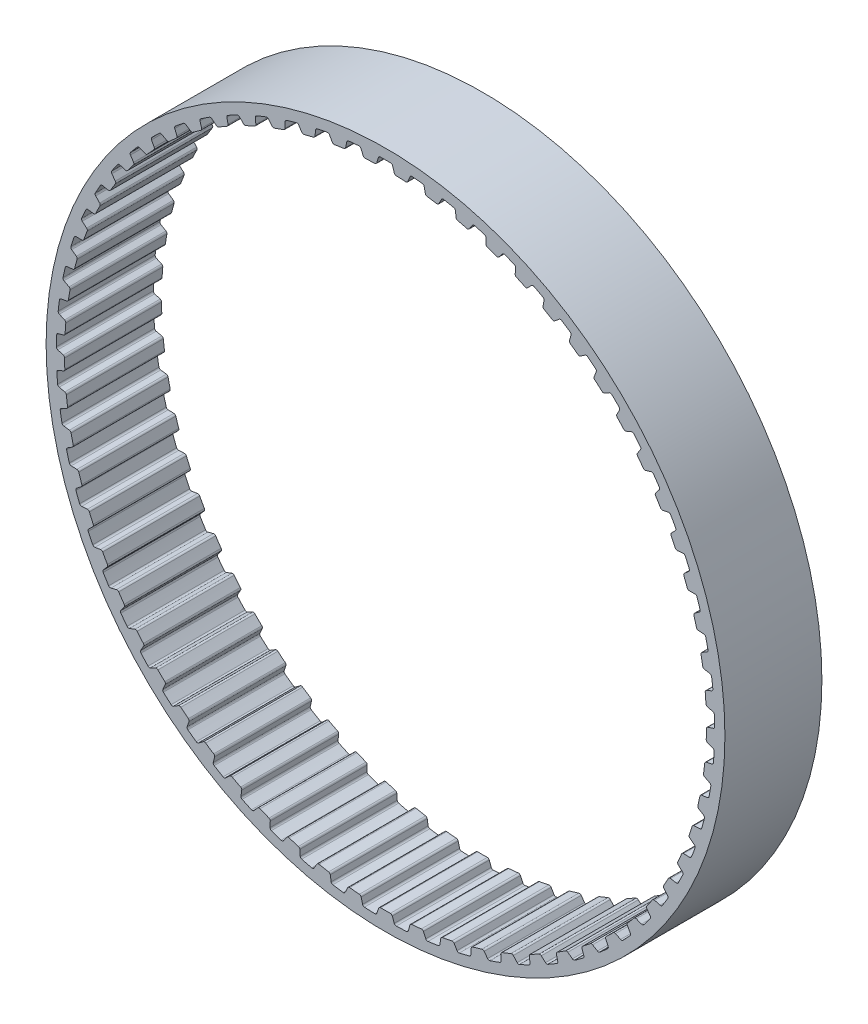
from build123d import *

# Parameters (mm, degrees)
SKETCH4_R           = 21.000512479
SKETCH4_R_2         = 19.857512479
BOSS_EXTRUDE1_DEPTH = 3
CUT_EXTRUDE1_DEPTH  = 3
CIRPATTERN1_COUNT   = 65


with BuildPart() as part:
    # Sketch4 → Boss-Extrude1 (new body, symmetric)
    with BuildSketch(Plane.XY):
        Circle(SKETCH4_R)
        Circle(SKETCH4_R_2, mode=Mode.SUBTRACT)
    extrude(amount=BOSS_EXTRUDE1_DEPTH, both=True)

    # Sketch3 → Cut-Extrude1 (cut, symmetric)
    with BuildSketch(Plane.XY):
        with BuildLine():
            Line((-0.661084211, 19.846505222), (0.661084211, 19.846505222))
            ThreePointArc((0.661084211, 19.846505222), (0.588283789, 19.872461456), (0.544012051, 19.935814756))
            Line((0.544012051, 19.935814756), (0.439240374, 20.273635027))
            ThreePointArc((0.439240374, 20.273635027), (0.394077748, 20.337661773), (0.319935334, 20.362999286))
            ThreePointArc((0.319935334, 20.362999286), (0, 20.365512479), (-0.319935334, 20.362999286))
            ThreePointArc((-0.319935334, 20.362999286), (-0.394077748, 20.337661773), (-0.439240374, 20.273635027))
            Line((-0.439240374, 20.273635027), (-0.544012051, 19.935814756))
            ThreePointArc((-0.544012051, 19.935814756), (-0.588283789, 19.872461456), (-0.661084211, 19.846505222))
        make_face()
    cut_extrude1 = extrude(amount=CUT_EXTRUDE1_DEPTH, both=True, mode=Mode.SUBTRACT)

    # CirPattern1: Cut-Extrude1 ×65 about axis
    cirpattern1_axis = Axis((0, 0, 0), (0, 0, 1))
    for i in range(1, CIRPATTERN1_COUNT):
        add(cut_extrude1.rotate(cirpattern1_axis, i * 360 / CIRPATTERN1_COUNT), mode=Mode.SUBTRACT)


solid = part.part
